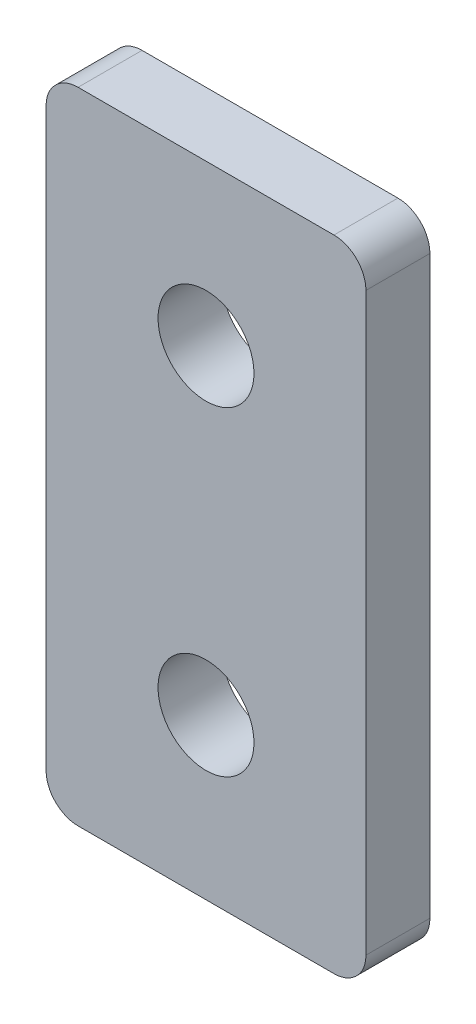
from build123d import *

# Parameters (mm, degrees)
SKETCH_1_W      = 10
SKETCH_1_H      = 20
SKETCH_1_R      = 1.5
EXTRUDE_1_DEPTH = 2
FILLET_1_R      = 1


with BuildPart() as part:
    # 草图1 → 凸台-拉伸1 (new body)
    with BuildSketch(Plane.XY):
        with Locations((1.642083631, -11.90903272)):
            Rectangle(SKETCH_1_W, SKETCH_1_H)
        with Locations((1.642083631, -6.90903272)):
            Circle(SKETCH_1_R, mode=Mode.SUBTRACT)
        with Locations((1.642083631, -16.90903272)):
            Circle(SKETCH_1_R, mode=Mode.SUBTRACT)
    extrude(amount=EXTRUDE_1_DEPTH)

    # 圆角1
    fillet_1_edges = [part.edges().sort_by_distance(p)[0] for p in [
        (-3.357916369, -1.90903272, 1),
        (6.642083631, -1.90903272, 1),
        (6.642083631, -21.90903272, 1),
        (-3.357916369, -21.90903272, 1),
    ]]
    fillet(fillet_1_edges, radius=FILLET_1_R)


solid = part.part
